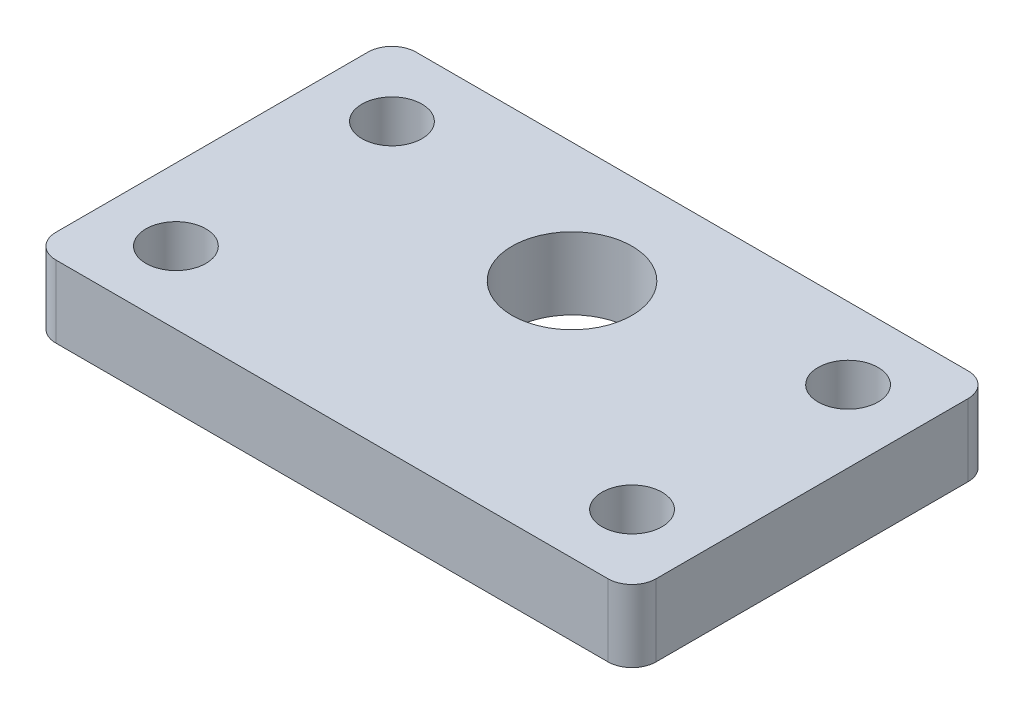
from build123d import *

# Parameters (mm, degrees)
BOSS_EXTRUDE1_DEPTH = 30
SKETCH2_R           = 25
SKETCH2_R_2         = 12.5
CUT_EXTRUDE1_DEPTH  = 31


with BuildPart() as part:
    # Sketch1 → Boss-Extrude1 (new body)
    with BuildSketch(Plane(origin=(0, 0, 0), x_dir=(1, 0, 0), z_dir=(0, 1, 0))):
        with BuildLine():
            Line((115, -75), (-115, -75))
            ThreePointArc((-115, -75), (-122.071067812, -72.071067812), (-125, -65))
            Line((-125, -65), (-125, 65))
            ThreePointArc((-125, 65), (-122.071067812, 72.071067812), (-115, 75))
            Line((-115, 75), (115, 75))
            ThreePointArc((115, 75), (122.071067812, 72.071067812), (125, 65))
            Line((125, 65), (125, -65))
            ThreePointArc((125, -65), (122.071067812, -72.071067812), (115, -75))
        make_face()
    extrude(amount=BOSS_EXTRUDE1_DEPTH)

    # Sketch2 → Cut-Extrude1 (cut, through all)
    with BuildSketch(Plane(origin=(0, 30, 0), x_dir=(1, 0, 0), z_dir=(0, 1, 0))):
        with Locations((0, 25)):
            Circle(SKETCH2_R)
        with Locations((-95, 45)):
            Circle(SKETCH2_R_2)
        with Locations((95, 45)):
            Circle(SKETCH2_R_2)
        with Locations((95, -45)):
            Circle(SKETCH2_R_2)
        with Locations((-95, -45)):
            Circle(SKETCH2_R_2)
    extrude(amount=-CUT_EXTRUDE1_DEPTH, mode=Mode.SUBTRACT)


solid = part.part
